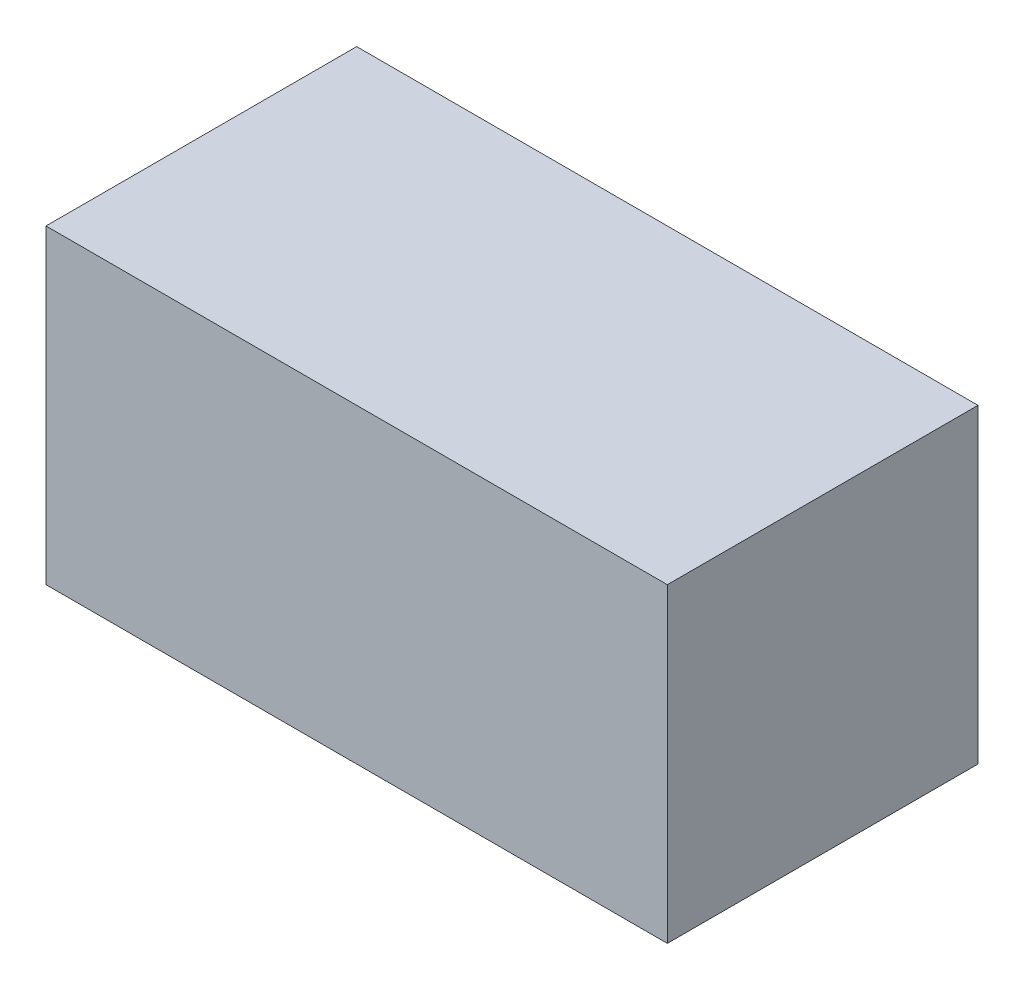
from build123d import *

# Parameters (mm, degrees)
CROQUIS1_W              = 10
CROQUIS1_H              = 5
SALIENTE_EXTRUIR1_DEPTH = 5


with BuildPart() as part:
    # Croquis1 → Saliente-Extruir1 (new body)
    with BuildSketch(Plane.XY):
        with Locations((-46.538635946, 28.055190592)):
            Rectangle(CROQUIS1_W, CROQUIS1_H)
    extrude(amount=SALIENTE_EXTRUIR1_DEPTH)


solid = part.part
